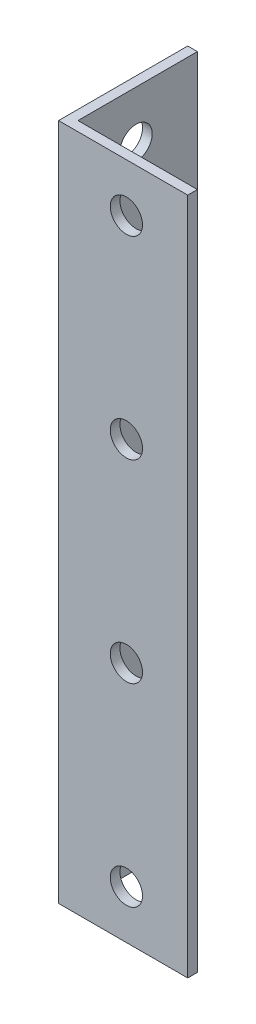
from build123d import *

# Parameters (mm, degrees)
EXTRUDE_1_DEPTH     = 210
SKETCH_2_R          = 5
CUT_EXTRUDE_1_DEPTH = 41
SKETCH_3_R          = 5
CUT_EXTRUDE_2_DEPTH = 41


with BuildPart() as part:
    # Эскиз1 → Вытянуть-Тонкостенный1 (new body)
    with BuildSketch(Plane(origin=(0, 0, 0), x_dir=(1, 0, 0), z_dir=(0, 1, 0))):
        Polygon((0, 40), (0, 0), (40, 0), (40, 3), (3, 3), (3, 40), align=None)
    extrude(amount=EXTRUDE_1_DEPTH)

    # Эскиз2 → Вырез-Вытянуть1 (cut, through all)
    with BuildSketch(Plane.ZY):
        with Locations((-21, 15)):
            Circle(SKETCH_2_R)
        with Locations((-21, 75)):
            Circle(SKETCH_2_R)
        with Locations((-21, 135)):
            Circle(SKETCH_2_R)
        with Locations((-21, 195)):
            Circle(SKETCH_2_R)
    extrude(amount=-CUT_EXTRUDE_1_DEPTH, mode=Mode.SUBTRACT)

    # Эскиз3 → Вырез-Вытянуть2 (cut, through all)
    with BuildSketch(Plane.XY):
        with Locations((21, 15)):
            Circle(SKETCH_3_R)
        with Locations((21, 75)):
            Circle(SKETCH_3_R)
        with Locations((21, 135)):
            Circle(SKETCH_3_R)
        with Locations((21, 195)):
            Circle(SKETCH_3_R)
    extrude(amount=-CUT_EXTRUDE_2_DEPTH, mode=Mode.SUBTRACT)


solid = part.part
